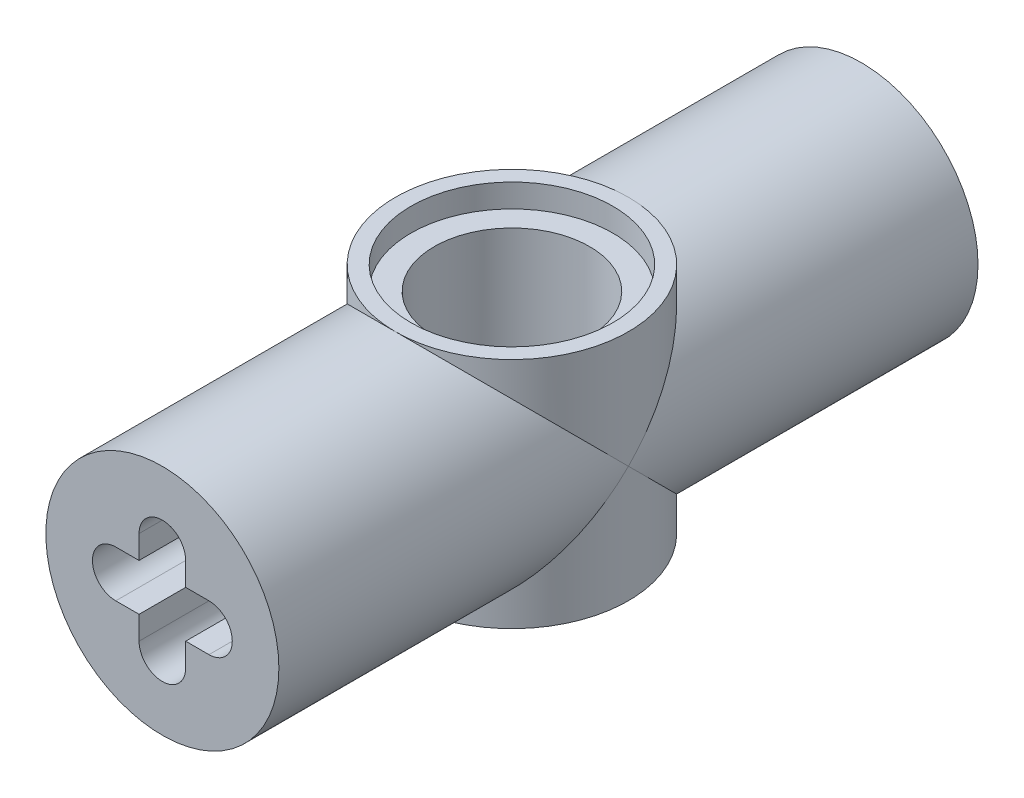
from build123d import *

# Parameters (mm, degrees)
SKETCH1_R                = 3.81
BOSS_EXTRUDE1_DEPTH      = 22.86
BOSS_EXTRUDE2_DEPTH      = 3.81
BOSS_EXTRUDE2_DEPTH_BACK = 3.81
SKETCH2_R                = 3.81
SKETCH4_R                = 2.54
CUT_EXTRUDE1_DEPTH       = 25.679861437
SKETCH5_R                = 3.302
CUT_EXTRUDE2_DEPTH       = 0.762
CUT_EXTRUDE3_START       = -0.762
SKETCH6_R                = 3.302
CUT_EXTRUDE3_DEPTH       = 0.762


with BuildPart() as part:
    # Sketch1 → Boss-Extrude1 (new body)
    with BuildSketch(Plane.XY):
        with Locations((1.524, 0)):
            Circle(SKETCH1_R)
        with BuildLine():
            ThreePointArc((0, -0.762), (-0.762, 0), (0, 0.762))
            Line((0, 0.762), (0.762, 0.762))
            Line((0.762, 0.762), (0.762, 1.524))
            ThreePointArc((0.762, 1.524), (1.524, 2.286), (2.286, 1.524))
            Line((2.286, 1.524), (2.286, 0.762))
            Line((2.286, 0.762), (3.048, 0.762))
            ThreePointArc((3.048, 0.762), (3.81, 0), (3.048, -0.762))
            Line((3.048, -0.762), (2.286, -0.762))
            Line((2.286, -0.762), (2.286, -1.524))
            ThreePointArc((2.286, -1.524), (1.524, -2.286), (0.762, -1.524))
            Line((0.762, -1.524), (0.762, -0.762))
            Line((0.762, -0.762), (0, -0.762))
        make_face(mode=Mode.SUBTRACT)
    extrude(amount=BOSS_EXTRUDE1_DEPTH)

    # Sketch2 → Boss-Extrude2 (add, two sides: drawn at the far end of the back side and taken through both)
    with BuildSketch(Plane(origin=(0, 0, 0), x_dir=(1, 0, 0), z_dir=(0, 1, 0)).offset(-BOSS_EXTRUDE2_DEPTH_BACK)):
        with Locations((1.524, -11.43)):
            Circle(SKETCH2_R)
    extrude(amount=BOSS_EXTRUDE2_DEPTH + BOSS_EXTRUDE2_DEPTH_BACK)

    # Sketch4 → Cut-Extrude1 (cut, through all)
    with BuildSketch(Plane(origin=(0, 3.81, 0), x_dir=(-1, 0, 0), z_dir=(0, 1, 0))):
        with Locations((-1.524, 11.43)):
            Circle(SKETCH4_R)
    extrude(amount=-CUT_EXTRUDE1_DEPTH, mode=Mode.SUBTRACT)

    # Sketch5 → Cut-Extrude2 (cut)
    with BuildSketch(Plane(origin=(0, 3.81, 0), x_dir=(1, 0, 0), z_dir=(0, 1, 0))):
        with Locations((1.524, -11.43)):
            Circle(SKETCH5_R)
    extrude(amount=-CUT_EXTRUDE2_DEPTH, mode=Mode.SUBTRACT)

    # Sketch6 → Cut-Extrude3 (cut)
    with BuildSketch(Plane.XZ.offset(3.81).offset(CUT_EXTRUDE3_START)):
        with Locations((1.524, 11.43)):
            Circle(SKETCH6_R)
    extrude(amount=CUT_EXTRUDE3_DEPTH, mode=Mode.SUBTRACT)


solid = part.part
